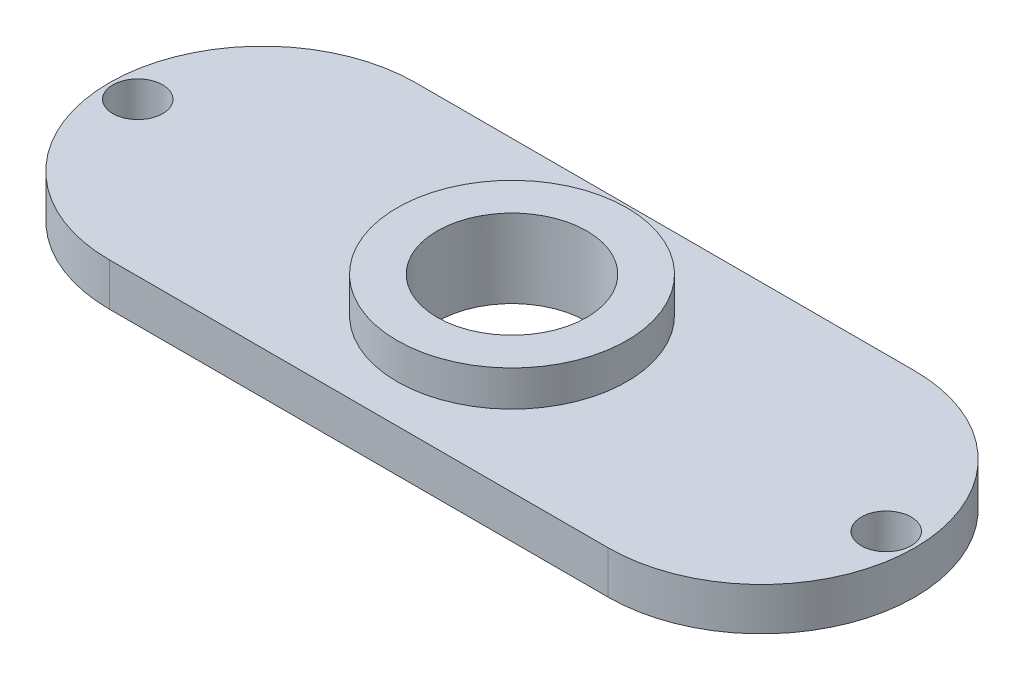
from build123d import *

# Parameters (mm, degrees)
SKETCH_1_R          = 6.45
SKETCH_1_R_2        = 4.2
EXTRUDE_1_DEPTH     = 2
SKETCH_2_R          = 4.2
EXTRUDE_3_DEPTH     = 2.4
SKETCH_3_R          = 1.4
CUT_EXTRUDE_1_DEPTH = 10


with BuildPart() as part:
    # 스케치1 → 보스-돌출1 (new body)
    with BuildSketch(Plane(origin=(0, 0, 0), x_dir=(1, 0, 0), z_dir=(0, 1, 0))):
        Circle(SKETCH_1_R)
        Circle(SKETCH_1_R_2, mode=Mode.SUBTRACT)
    extrude(amount=EXTRUDE_1_DEPTH)

    # 스케치2 → 보스-돌출3 (add)
    with BuildSketch(Plane.XZ):
        with BuildLine():
            Line((-14, 8.6), (14, 8.6))
            ThreePointArc((14, 8.6), (22.6, 0), (14, -8.6))
            Line((14, -8.6), (-14, -8.6))
            ThreePointArc((-14, -8.6), (-22.6, 0), (-14, 8.6))
        make_face()
        Circle(SKETCH_2_R, mode=Mode.SUBTRACT)
    extrude(amount=EXTRUDE_3_DEPTH)

    # 스케치3 → 컷-돌출1 (cut)
    with BuildSketch(Plane.XZ.offset(2.4)):
        with Locations((-21, 0)):
            Circle(SKETCH_3_R)
    cut_extrude_1 = extrude(amount=-CUT_EXTRUDE_1_DEPTH, mode=Mode.SUBTRACT)

    # 대칭 복사1: 컷-돌출1 across plane
    add(cut_extrude_1.mirror(Plane(origin=(0, 0, 0), x_dir=(0, 0, 1), z_dir=(1, 0, 0))), mode=Mode.SUBTRACT)


solid = part.part
